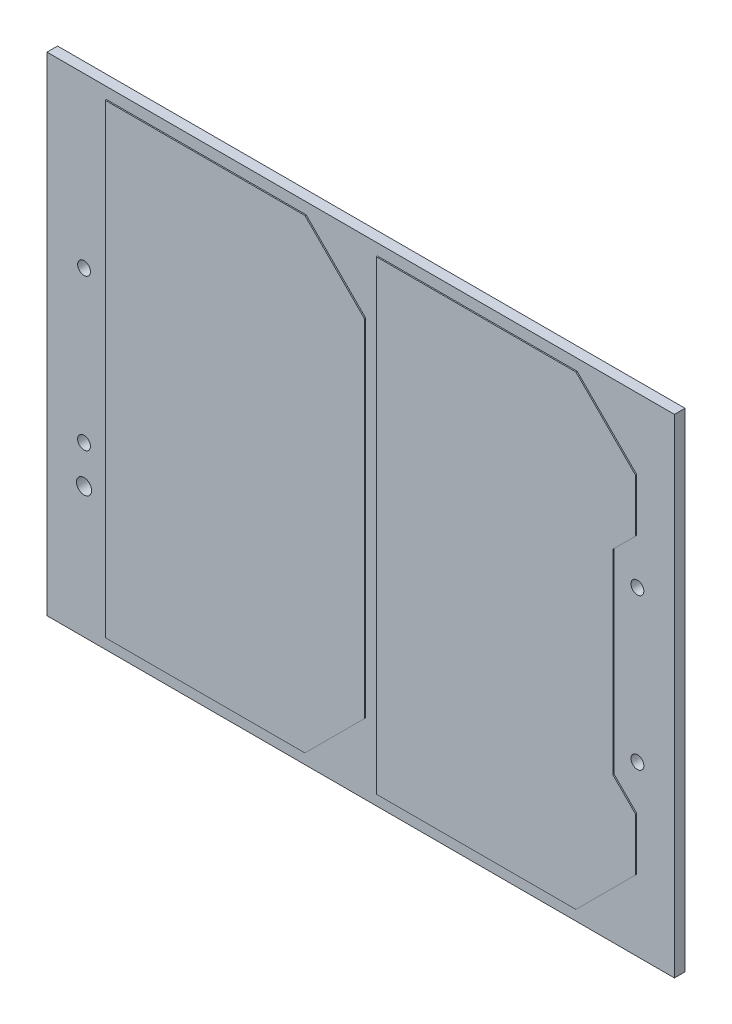
from build123d import *

# Parameters (mm, degrees)
SKETCH1_W           = 105.41
SKETCH1_H           = 82
SKETCH1_R           = 1.0795
SKETCH1_R_2         = 1.27
BOSS_EXTRUDE1_DEPTH = 1.778
BOSS_EXTRUDE2_DEPTH = 0.2


with BuildPart() as part:
    # Sketch1 → Boss-Extrude1 (new body)
    with BuildSketch(Plane.XY):
        Rectangle(SKETCH1_W, SKETCH1_H)
        with Locations((46.482, 12.7)):
            Circle(SKETCH1_R, mode=Mode.SUBTRACT)
        with Locations((46.482, -12.7)):
            Circle(SKETCH1_R, mode=Mode.SUBTRACT)
        with Locations((-46.482, 12.7)):
            Circle(SKETCH1_R, mode=Mode.SUBTRACT)
        with Locations((-46.482, -12.7)):
            Circle(SKETCH1_R, mode=Mode.SUBTRACT)
        with Locations((-46.482, -19.05)):
            Circle(SKETCH1_R_2, mode=Mode.SUBTRACT)
    extrude(amount=BOSS_EXTRUDE1_DEPTH)

    # Sketch2 → Boss-Extrude2 (add)
    with BuildSketch(Plane.XY.offset(1.778)):
        Polygon((-9.175, 39.095), (0.825, 29.095), (0.825, -29.095), (-9.175, -39.095), (-42.705, -39.095), (-42.705, 39.095), align=None)
        Polygon((46.355, 20.205), (42.545, 16.395), (42.545, -16.395), (46.355, -20.205), (46.355, -29.095), (36.355, -39.095), (2.825, -39.095), (2.825, 39.095), (36.355, 39.095), (46.355, 29.095), align=None)
    extrude(amount=BOSS_EXTRUDE2_DEPTH)


solid = part.part
